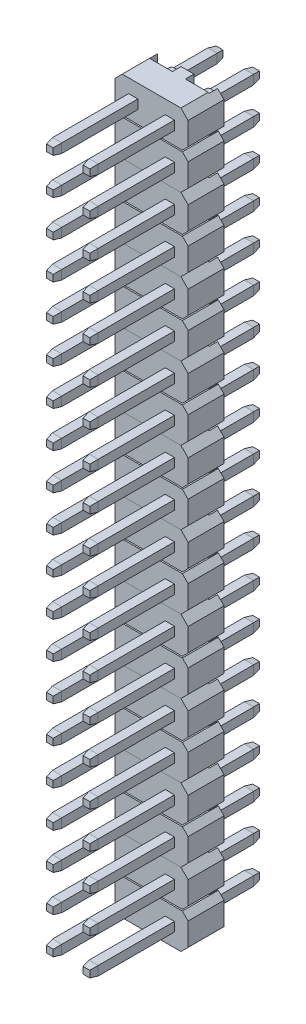
from build123d import *

# Parameters (mm, degrees)
SKETCH1_W             = 0.64
SKETCH1_H             = 0.64
BOSS_EXTRUDE1_DEPTH   = 5.3
BOSS_EXTRUDE1_2_DEPTH = 5.3
BOSS_EXTRUDE1_3_DEPTH = 5.3
BOSS_EXTRUDE1_4_DEPTH = 5.3
SKETCH2_W             = 0.64
SKETCH2_H             = 0.64
BOSS_EXTRUDE2_DEPTH   = 0.5
BOSS_EXTRUDE2_TAPER   = 10
BOSS_EXTRUDE3_DEPTH   = 2.5
SKETCH5_W             = 1.64
SKETCH5_H             = 5.08
CUT_EXTRUDE1_DEPTH    = 0.6
SKETCH6_W             = 5.08
SKETCH6_H             = 0.1
CUT_EXTRUDE2_DEPTH    = 3.5
CUT_EXTRUDE3_DEPTH    = 3.5
SKETCH8_W             = 0.64
SKETCH8_H             = 0.64
BOSS_EXTRUDE4_DEPTH   = 3.6
BOSS_EXTRUDE4_2_DEPTH = 3.6
BOSS_EXTRUDE4_3_DEPTH = 3.6
BOSS_EXTRUDE4_4_DEPTH = 3.6
SKETCH9_W             = 0.64
SKETCH9_H             = 0.64
BOSS_EXTRUDE5_DEPTH   = 0.5
BOSS_EXTRUDE5_TAPER   = 10
LPATTERN1_COUNT       = 10
LPATTERN1_PITCH       = 5.08
SKETCH10_R            = 0.56
BOSS_EXTRUDE6_DEPTH   = 1
BOSS_EXTRUDE6_2_DEPTH = 1


with BuildPart() as part:
    # Sketch1 → Boss-Extrude1 (new body)
    with BuildSketch(Plane.XY):
        with Locations((-1.27, 1.27)):
            Rectangle(SKETCH1_W, SKETCH1_H)
    extrude(amount=BOSS_EXTRUDE1_DEPTH)



with BuildPart() as body_2:
    # Sketch1 → Boss-Extrude1 2 (new body)
    with BuildSketch(Plane.XY):
        with Locations((-1.27, -1.27)):
            Rectangle(SKETCH1_W, SKETCH1_H)
    extrude(amount=BOSS_EXTRUDE1_2_DEPTH)


with BuildPart() as body_3:
    # Sketch1 → Boss-Extrude1 3 (new body)
    with BuildSketch(Plane.XY):
        with Locations((1.27, 1.27)):
            Rectangle(SKETCH1_W, SKETCH1_H)
    extrude(amount=BOSS_EXTRUDE1_3_DEPTH)


with BuildPart() as body_4:
    # Sketch1 → Boss-Extrude1 4 (new body)
    with BuildSketch(Plane.XY):
        with Locations((1.27, -1.27)):
            Rectangle(SKETCH1_W, SKETCH1_H)
    extrude(amount=BOSS_EXTRUDE1_4_DEPTH)


with BuildPart() as part_1:
    add(part.part)

    add(body_2.part)  # Boss-Extrude2 merges body 2

    add(body_3.part)  # Boss-Extrude2 merges body 3

    add(body_4.part)  # Boss-Extrude2 merges body 4
    # Sketch2 → Boss-Extrude2 (add)
    with BuildSketch(Plane.XY.offset(5.3)):
        with Locations((-1.27, -1.27)):
            Rectangle(SKETCH2_W, SKETCH2_H)
        with Locations((-1.27, 1.27)):
            Rectangle(SKETCH2_W, SKETCH2_H)
        with Locations((1.27, -1.27)):
            Rectangle(SKETCH2_W, SKETCH2_H)
        with Locations((1.27, 1.27)):
            Rectangle(SKETCH2_W, SKETCH2_H)
    extrude(amount=BOSS_EXTRUDE2_DEPTH, taper=BOSS_EXTRUDE2_TAPER)


with BuildPart() as body_2_2:
    # Sketch3 → Boss-Extrude3 (new body)
    with BuildSketch(Plane.XY):
        Polygon((-2.04, 2.54), (2.04, 2.54), (2.54, 2.04), (2.54, -2.04), (2.04, -2.54), (-2.04, -2.54), (-2.54, -2.04), (-2.54, 2.04), align=None)
    extrude(amount=-BOSS_EXTRUDE3_DEPTH)

    # Sketch5 → Cut-Extrude1 (cut)
    with BuildSketch(Plane(origin=(0, 0, -2.5), x_dir=(-1, 0, 0), z_dir=(0, 0, -1))):
        with Locations((-1.27, 0)):
            Rectangle(SKETCH5_W, SKETCH5_H)
        with Locations((1.27, 0)):
            Rectangle(SKETCH5_W, SKETCH5_H)
    extrude(amount=-CUT_EXTRUDE1_DEPTH, mode=Mode.SUBTRACT)

    # Sketch6 → Cut-Extrude2 (cut, through all)
    with BuildSketch(Plane.XY):
        Rectangle(SKETCH6_W, SKETCH6_H)
    extrude(amount=-CUT_EXTRUDE2_DEPTH, mode=Mode.SUBTRACT)

    # Sketch7 → Cut-Extrude3 (cut, through all)
    with BuildSketch(Plane.XY):
        Polygon((2.54, 0.45), (2.14, 0.05), (2.54, 0.05), align=None)
        Polygon((2.54, -0.05), (2.14, -0.05), (2.54, -0.45), align=None)
        Polygon((-2.54, -0.45), (-2.54, -0.05), (-2.14, -0.05), align=None)
        Polygon((-2.54, 0.05), (-2.54, 0.45), (-2.14, 0.05), align=None)
    extrude(amount=-CUT_EXTRUDE3_DEPTH, mode=Mode.SUBTRACT)


with BuildPart() as body_3_2:
    # Sketch8 → Boss-Extrude4 (new body)
    with BuildSketch(Plane(origin=(0, 0, -1.9), x_dir=(-1, 0, 0), z_dir=(0, 0, -1))):
        with Locations((1.27, -1.27)):
            Rectangle(SKETCH8_W, SKETCH8_H)
    extrude(amount=BOSS_EXTRUDE4_DEPTH)



with BuildPart() as body_4_2:
    # Sketch8 → Boss-Extrude4 2 (new body)
    with BuildSketch(Plane(origin=(0, 0, -1.9), x_dir=(-1, 0, 0), z_dir=(0, 0, -1))):
        with Locations((1.27, 1.27)):
            Rectangle(SKETCH8_W, SKETCH8_H)
    extrude(amount=BOSS_EXTRUDE4_2_DEPTH)


with BuildPart() as body_5:
    # Sketch8 → Boss-Extrude4 3 (new body)
    with BuildSketch(Plane(origin=(0, 0, -1.9), x_dir=(-1, 0, 0), z_dir=(0, 0, -1))):
        with Locations((-1.27, 1.27)):
            Rectangle(SKETCH8_W, SKETCH8_H)
    extrude(amount=BOSS_EXTRUDE4_3_DEPTH)


with BuildPart() as body_6:
    # Sketch8 → Boss-Extrude4 4 (new body)
    with BuildSketch(Plane(origin=(0, 0, -1.9), x_dir=(-1, 0, 0), z_dir=(0, 0, -1))):
        with Locations((-1.27, -1.27)):
            Rectangle(SKETCH8_W, SKETCH8_H)
    extrude(amount=BOSS_EXTRUDE4_4_DEPTH)


with BuildPart() as body_3_2_1:
    add(body_3_2.part)

    add(body_4_2.part)  # Boss-Extrude5 merges body 4 2

    add(body_5.part)  # Boss-Extrude5 merges body 5

    add(body_6.part)  # Boss-Extrude5 merges body 6
    # Sketch9 → Boss-Extrude5 (add)
    with BuildSketch(Plane(origin=(0, 0, -5.5), x_dir=(-1, 0, 0), z_dir=(0, 0, -1))):
        with Locations((1.27, 1.27)):
            Rectangle(SKETCH9_W, SKETCH9_H)
        with Locations((1.27, -1.27)):
            Rectangle(SKETCH9_W, SKETCH9_H)
        with Locations((-1.27, -1.27)):
            Rectangle(SKETCH9_W, SKETCH9_H)
        with Locations((-1.27, 1.27)):
            Rectangle(SKETCH9_W, SKETCH9_H)
    extrude(amount=BOSS_EXTRUDE5_DEPTH, taper=BOSS_EXTRUDE5_TAPER)


with BuildPart() as lpattern1_1:
    # LPattern1: pattern copy
    add(part_1.part.moved(Location(Vector(0, -1, 0) * (1 * LPATTERN1_PITCH))))


with BuildPart() as lpattern1_2:
    # LPattern1: pattern copy
    add(part_1.part.moved(Location(Vector(0, -1, 0) * (2 * LPATTERN1_PITCH))))


with BuildPart() as lpattern1_3:
    # LPattern1: pattern copy
    add(part_1.part.moved(Location(Vector(0, -1, 0) * (3 * LPATTERN1_PITCH))))


with BuildPart() as lpattern1_4:
    # LPattern1: pattern copy
    add(part_1.part.moved(Location(Vector(0, -1, 0) * (4 * LPATTERN1_PITCH))))


with BuildPart() as lpattern1_5:
    # LPattern1: pattern copy
    add(part_1.part.moved(Location(Vector(0, -1, 0) * (5 * LPATTERN1_PITCH))))


with BuildPart() as lpattern1_6:
    # LPattern1: pattern copy
    add(part_1.part.moved(Location(Vector(0, -1, 0) * (6 * LPATTERN1_PITCH))))


with BuildPart() as lpattern1_7:
    # LPattern1: pattern copy
    add(part_1.part.moved(Location(Vector(0, -1, 0) * (7 * LPATTERN1_PITCH))))


with BuildPart() as lpattern1_8:
    # LPattern1: pattern copy
    add(part_1.part.moved(Location(Vector(0, -1, 0) * (8 * LPATTERN1_PITCH))))


with BuildPart() as lpattern1_9:
    # LPattern1: pattern copy
    add(part_1.part.moved(Location(Vector(0, -1, 0) * (9 * LPATTERN1_PITCH))))


with BuildPart() as lpattern1_10:
    # LPattern1: pattern copy
    add(body_3_2_1.part.moved(Location(Vector(0, -1, 0) * (1 * LPATTERN1_PITCH))))


with BuildPart() as lpattern1_11:
    # LPattern1: pattern copy
    add(body_3_2_1.part.moved(Location(Vector(0, -1, 0) * (2 * LPATTERN1_PITCH))))


with BuildPart() as lpattern1_12:
    # LPattern1: pattern copy
    add(body_3_2_1.part.moved(Location(Vector(0, -1, 0) * (3 * LPATTERN1_PITCH))))


with BuildPart() as lpattern1_13:
    # LPattern1: pattern copy
    add(body_3_2_1.part.moved(Location(Vector(0, -1, 0) * (4 * LPATTERN1_PITCH))))


with BuildPart() as lpattern1_14:
    # LPattern1: pattern copy
    add(body_3_2_1.part.moved(Location(Vector(0, -1, 0) * (5 * LPATTERN1_PITCH))))


with BuildPart() as lpattern1_15:
    # LPattern1: pattern copy
    add(body_3_2_1.part.moved(Location(Vector(0, -1, 0) * (6 * LPATTERN1_PITCH))))


with BuildPart() as lpattern1_16:
    # LPattern1: pattern copy
    add(body_3_2_1.part.moved(Location(Vector(0, -1, 0) * (7 * LPATTERN1_PITCH))))


with BuildPart() as lpattern1_17:
    # LPattern1: pattern copy
    add(body_3_2_1.part.moved(Location(Vector(0, -1, 0) * (8 * LPATTERN1_PITCH))))


with BuildPart() as lpattern1_18:
    # LPattern1: pattern copy
    add(body_3_2_1.part.moved(Location(Vector(0, -1, 0) * (9 * LPATTERN1_PITCH))))


with BuildPart() as lpattern1_19:
    # LPattern1: pattern copy
    add(body_2_2.part.moved(Location(Vector(0, -1, 0) * (1 * LPATTERN1_PITCH))))


with BuildPart() as lpattern1_20:
    # LPattern1: pattern copy
    add(body_2_2.part.moved(Location(Vector(0, -1, 0) * (2 * LPATTERN1_PITCH))))


with BuildPart() as lpattern1_21:
    # LPattern1: pattern copy
    add(body_2_2.part.moved(Location(Vector(0, -1, 0) * (3 * LPATTERN1_PITCH))))


with BuildPart() as lpattern1_22:
    # LPattern1: pattern copy
    add(body_2_2.part.moved(Location(Vector(0, -1, 0) * (4 * LPATTERN1_PITCH))))


with BuildPart() as lpattern1_23:
    # LPattern1: pattern copy
    add(body_2_2.part.moved(Location(Vector(0, -1, 0) * (5 * LPATTERN1_PITCH))))


with BuildPart() as lpattern1_24:
    # LPattern1: pattern copy
    add(body_2_2.part.moved(Location(Vector(0, -1, 0) * (6 * LPATTERN1_PITCH))))


with BuildPart() as lpattern1_25:
    # LPattern1: pattern copy
    add(body_2_2.part.moved(Location(Vector(0, -1, 0) * (7 * LPATTERN1_PITCH))))


with BuildPart() as lpattern1_26:
    # LPattern1: pattern copy
    add(body_2_2.part.moved(Location(Vector(0, -1, 0) * (8 * LPATTERN1_PITCH))))


with BuildPart() as lpattern1_27:
    # LPattern1: pattern copy
    add(body_2_2.part.moved(Location(Vector(0, -1, 0) * (9 * LPATTERN1_PITCH))))


with BuildPart() as body_31:
    # Sketch10 → Boss-Extrude6 (new body)
    with BuildSketch(Plane(origin=(0, 0, -1.9), x_dir=(-1, 0, 0), z_dir=(0, 0, -1))):
        with Locations((-1.27, 1.27)):
            Circle(SKETCH10_R)
    extrude(amount=BOSS_EXTRUDE6_DEPTH)


with BuildPart() as body_32:
    # Sketch10 → Boss-Extrude6 2 (new body)
    with BuildSketch(Plane(origin=(0, 0, -1.9), x_dir=(-1, 0, 0), z_dir=(0, 0, -1))):
        with Locations((1.27, 1.27)):
            Circle(SKETCH10_R)
    extrude(amount=BOSS_EXTRUDE6_2_DEPTH)


solid = Compound([part_1.part, body_2_2.part, body_3_2_1.part, lpattern1_1.part, lpattern1_2.part, lpattern1_3.part, lpattern1_4.part, lpattern1_5.part, lpattern1_6.part, lpattern1_7.part, lpattern1_8.part, lpattern1_9.part, lpattern1_10.part, lpattern1_11.part, lpattern1_12.part, lpattern1_13.part, lpattern1_14.part, lpattern1_15.part, lpattern1_16.part, lpattern1_17.part, lpattern1_18.part, lpattern1_19.part, lpattern1_20.part, lpattern1_21.part, lpattern1_22.part, lpattern1_23.part, lpattern1_24.part, lpattern1_25.part, lpattern1_26.part, lpattern1_27.part, body_31.part, body_32.part])
